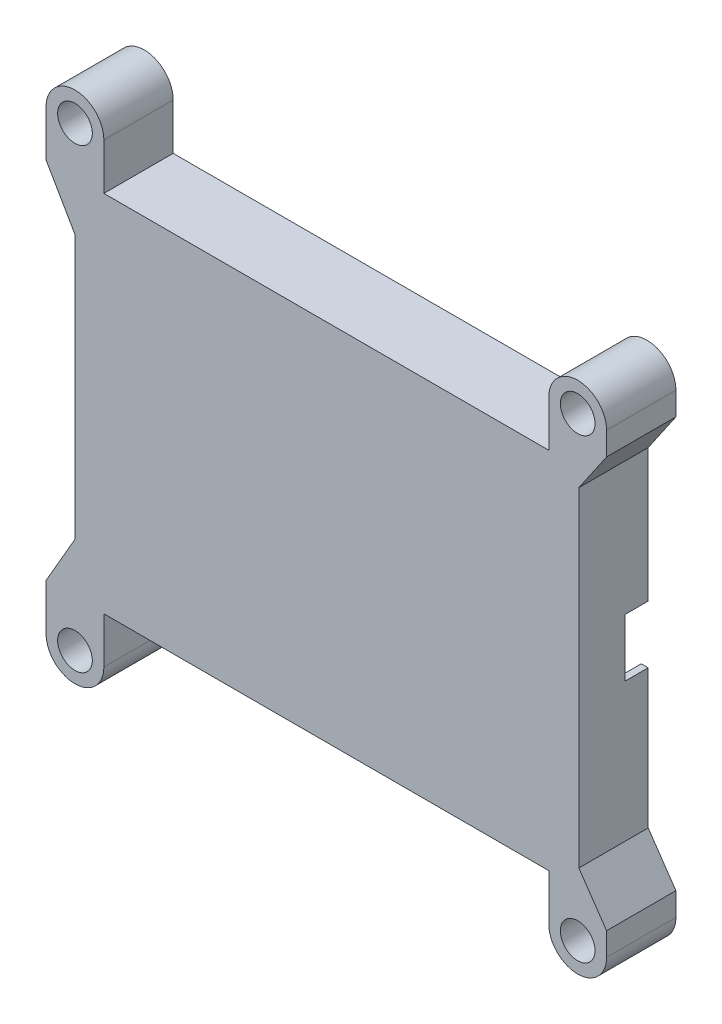
from build123d import *

# Parameters (mm, degrees)
EXTRUDE_1_DEPTH     = 2
SKETCH_2_W          = 50
SKETCH_2_H          = 27
EXTRUDE_2_DEPTH     = 10
SKETCH_3_R          = 3
CUT_EXTRUDE_1_DEPTH = 13
SKETCH_5_W          = 47
SKETCH_5_H          = 1.6
CUT_EXTRUDE_2_DEPTH = 1.6
SKETCH_6_W          = 4
SKETCH_6_H          = 10
CUT_EXTRUDE_3_DEPTH = 7
SKETCH_7_W          = 80
SKETCH_7_H          = 14.002207555
CUT_EXTRUDE_4_DEPTH = 10
CUT_EXTRUDE_5_REACH = 14


with BuildPart() as part:
    # 草图1 → 凸台-拉伸1 (new body)
    with BuildSketch(Plane.XY):
        with BuildLine():
            Line((-46, 22.841953517), (-46, -22.841953517))
            Line((-46, -22.841953517), (-51, -31.502207555))
            Line((-51, -31.502207555), (-51, -39.502207555))
            ThreePointArc((-51, -39.502207555), (-46, -44.502207555), (-41, -39.502207555))
            Line((-41, -39.502207555), (-41, -31.502207555))
            Line((-41, -31.502207555), (36, -31.502207555))
            Line((36, -31.502207555), (36, -39.502207555))
            ThreePointArc((36, -39.502207555), (41, -44.502207555), (46, -39.502207555))
            Line((46, -39.502207555), (46, 39.502207555))
            ThreePointArc((46, 39.502207555), (41, 44.502207555), (36, 39.502207555))
            Line((36, 39.502207555), (36, 31.502207555))
            Line((36, 31.502207555), (-41, 31.502207555))
            Line((-41, 31.502207555), (-41, 39.502207555))
            ThreePointArc((-41, 39.502207555), (-46, 44.502207555), (-51, 39.502207555))
            Line((-51, 39.502207555), (-51, 31.502207555))
            Line((-51, 31.502207555), (-46, 22.841953517))
        make_face()
    extrude(amount=EXTRUDE_1_DEPTH)

    # 草图2 → 凸台-拉伸2 (add)
    with BuildSketch(Plane(origin=(0, 0, 0), x_dir=(-1, 0, 0), z_dir=(0, 0, -1))):
        with BuildLine():
            Line((46, -22.841953517), (46, 22.841953517))
            Line((46, 22.841953517), (51, 31.502207555))
            Line((51, 31.502207555), (51, 39.502207555))
            ThreePointArc((51, 39.502207555), (46, 44.502207555), (41, 39.502207555))
            Line((41, 39.502207555), (41, 31.502207555))
            Line((41, 31.502207555), (-36, 31.502207555))
            Line((-36, 31.502207555), (-36, 39.502207555))
            ThreePointArc((-36, 39.502207555), (-41, 44.502207555), (-46, 39.502207555))
            Line((-46, 39.502207555), (-46, -39.502207555))
            ThreePointArc((-46, -39.502207555), (-41, -44.502207555), (-36, -39.502207555))
            Line((-36, -39.502207555), (-36, -31.502207555))
            Line((-36, -31.502207555), (41, -31.502207555))
            Line((41, -31.502207555), (41, -39.502207555))
            ThreePointArc((41, -39.502207555), (46, -44.502207555), (51, -39.502207555))
            Line((51, -39.502207555), (51, -31.502207555))
            Line((51, -31.502207555), (46, -22.841953517))
        make_face()
        with Locations((-15, 0)):
            Rectangle(SKETCH_2_W, SKETCH_2_H, mode=Mode.SUBTRACT)
    extrude(amount=EXTRUDE_2_DEPTH)

    # 草图3 → 切除-拉伸1 (cut, through all)
    with BuildSketch(Plane(origin=(0, 0, -10), x_dir=(-1, 0, 0), z_dir=(0, 0, -1))):
        with Locations((-41, 39.502207555)):
            Circle(SKETCH_3_R)
        with Locations((46, -39.502207555)):
            Circle(SKETCH_3_R)
        with Locations((46, 39.502207555)):
            Circle(SKETCH_3_R)
        with Locations((-41, -39.502207555)):
            Circle(SKETCH_3_R)
    extrude(amount=-CUT_EXTRUDE_1_DEPTH, mode=Mode.SUBTRACT)

    # 草图5 → 切除-拉伸2 (cut)
    with BuildSketch(Plane(origin=(0, 0, 0), x_dir=(-1, 0, 0), z_dir=(0, 0, -1))):
        with Locations((-15.3, 10.95)):
            Rectangle(SKETCH_5_W, SKETCH_5_H)
        with Locations((-15.3, -10.95)):
            Rectangle(SKETCH_5_W, SKETCH_5_H)
    extrude(amount=-CUT_EXTRUDE_2_DEPTH, mode=Mode.SUBTRACT)

    # 草图6 → 切除-拉伸3 (cut, through all)
    with BuildSketch(Plane.ZY.offset(-40)):
        with Locations((-8, 0.5)):
            Rectangle(SKETCH_6_W, SKETCH_6_H)
    extrude(amount=-CUT_EXTRUDE_3_DEPTH, mode=Mode.SUBTRACT)

    # 草图7 → 切除-拉伸4 (cut)
    with BuildSketch(Plane(origin=(0, 0, -10), x_dir=(-1, 0, 0), z_dir=(0, 0, -1))):
        with Locations((4, -22.501103778)):
            Rectangle(SKETCH_7_W, SKETCH_7_H)
        Polygon((12, -15.5), (44, -15.5), (44, 29.502207555), (-36, 29.502207555), (-36, 15.5), (12, 15.5), align=None)
    extrude(amount=-CUT_EXTRUDE_4_DEPTH, mode=Mode.SUBTRACT)

    # 草图9 → 切除-拉伸5 (cut, up to next)
    with BuildSketch(Plane(origin=(0, 0, -10), x_dir=(-1, 0, 0), z_dir=(0, 0, -1)), mode=Mode.PRIVATE) as cut_extrude_5_sk1:
        Polygon((-46, -35.502207555), (-41.2, -28.502207555), (-41.2, 28.502207555), (-46, 35.502207555), align=None)
    cut_extrude_5_tool1 = extrude(cut_extrude_5_sk1.sketch, amount=-CUT_EXTRUDE_5_REACH, mode=Mode.PRIVATE) & part.part
    add(cut_extrude_5_tool1.solids().sort_by_distance((43.687494, 0, -10))[0], mode=Mode.SUBTRACT)


solid = part.part
